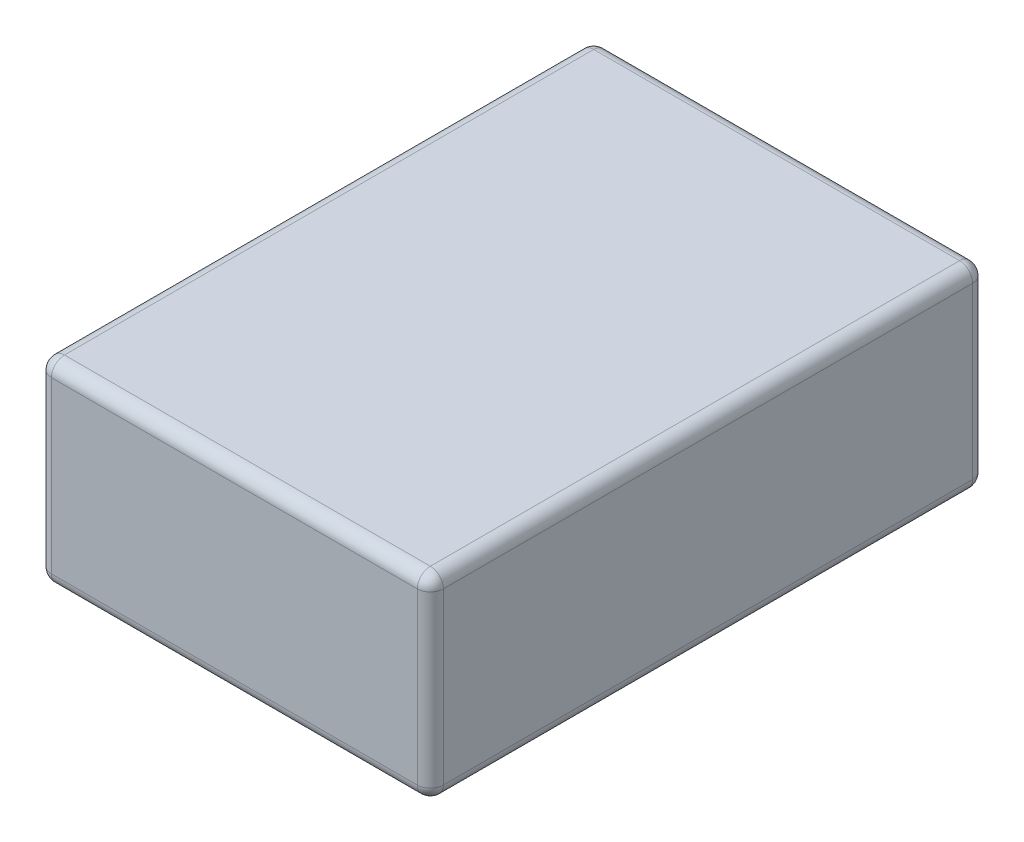
from build123d import *

# Parameters (mm, degrees)
EXTRUDE_1_DEPTH = 30
FILLET_1_R      = 2


with BuildPart() as part:
    # 草图1 → 凸台-拉伸1 (new body)
    with BuildSketch(Plane(origin=(0, 0, 0), x_dir=(1, 0, 0), z_dir=(0, 1, 0))):
        with BuildLine():
            Line((-28, 42.5), (28, 42.5))
            ThreePointArc((28, 42.5), (29.414213562, 41.914213562), (30, 40.5))
            Line((30, 40.5), (30, -40.5))
            ThreePointArc((30, -40.5), (29.414213562, -41.914213562), (28, -42.5))
            Line((28, -42.5), (-28, -42.5))
            ThreePointArc((-28, -42.5), (-29.414213562, -41.914213562), (-30, -40.5))
            Line((-30, -40.5), (-30, 40.5))
            ThreePointArc((-30, 40.5), (-29.414213562, 41.914213562), (-28, 42.5))
        make_face()
    extrude(amount=EXTRUDE_1_DEPTH)

    # 圆角1
    fillet_1_edges = [part.edges().sort_by_distance(p)[0] for p in [
        (29.414213562, 30, 41.914213562),
        (0, 0, 42.5),
        (-29.414213562, 0, 41.914213562),
        (30, 30, 0),
        (29.414213562, 30, -41.914213562),
        (0, 30, -42.5),
        (-29.414213562, 30, -41.914213562),
        (-30, 30, 0),
        (-29.414213562, 30, 41.914213562),
        (0, 30, 42.5),
        (-30, 0, 0),
        (-29.414213562, 0, -41.914213562),
        (0, 0, -42.5),
        (29.414213562, 0, -41.914213562),
        (30, 0, 0),
        (29.414213562, 0, 41.914213562),
    ]]
    fillet(fillet_1_edges, radius=FILLET_1_R)


solid = part.part
